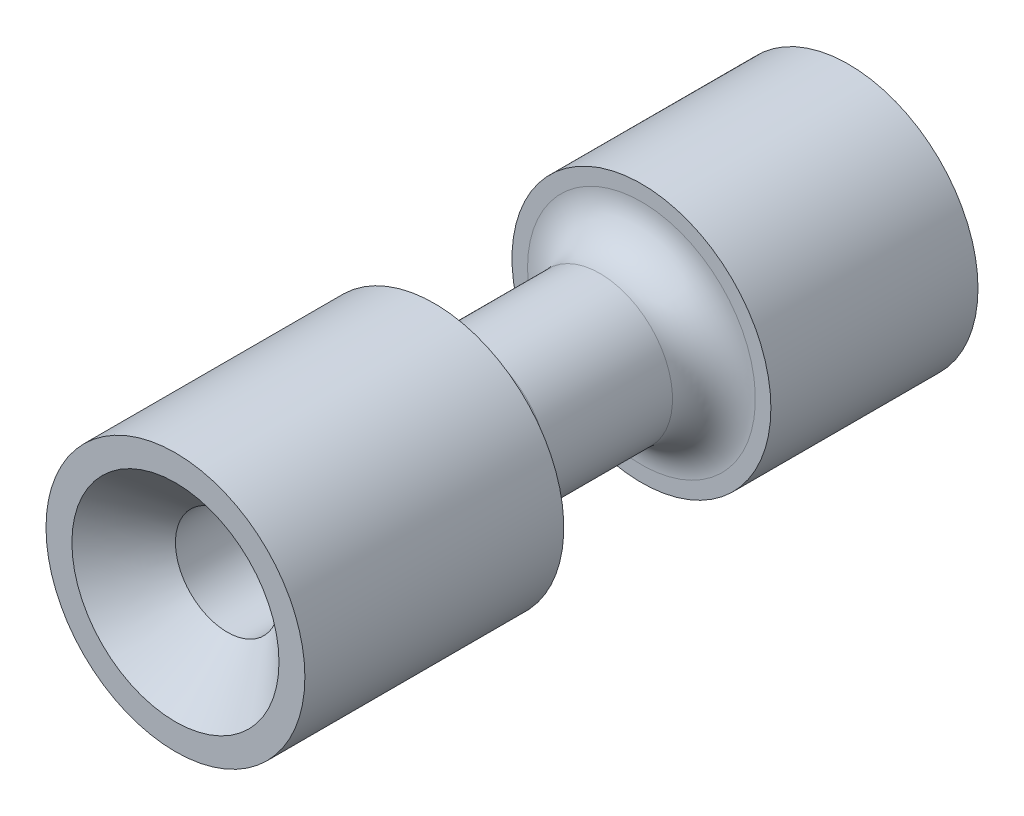
from build123d import *

# Parameters (mm, degrees)
SKETCH1_R                = 2.5
BOSS_EXTRUDE1_DEPTH      = 13
F_2_0_2_DIAMETER_HOLE1_D = 2
CHAMFER2_SIZE            = 1


with BuildPart() as part:
    # Sketch1 → Boss-Extrude1 (new body)
    with BuildSketch(Plane.XY):
        Circle(SKETCH1_R)
    extrude(amount=BOSS_EXTRUDE1_DEPTH)

    # Sketch3 → Cut-Revolve1 (revolve, cut)
    with BuildSketch(Plane(origin=(0, 0, 0), x_dir=(1, 0, 0), z_dir=(0, 1, 0))):
        with BuildLine():
            Line((3.138230266, -4), (2.2, -4))
            ThreePointArc((2.2, -4), (1.634314575, -4.234314575), (1.4, -4.8))
            Line((1.4, -4.8), (1.4, -7.2))
            ThreePointArc((1.4, -7.2), (1.634314575, -7.765685425), (2.2, -8))
            Line((2.2, -8), (3.138230266, -8))
            Line((3.138230266, -8), (3.138230266, -4))
        make_face()
    revolve(axis=Axis((0, 0, 0), (0, 0, 1)), mode=Mode.SUBTRACT)

    # Ø2.0 (2) Diameter Hole1 (through all)
    with Locations(Plane.XY.offset(13)):
        with Locations((0, 0)):
            Hole(F_2_0_2_DIAMETER_HOLE1_D / 2)

    # Chamfer2
    chamfer2_edges = [part.edges().sort_by_distance(p)[0] for p in [
        (1, 0, 13),
    ]]
    chamfer(chamfer2_edges, length=CHAMFER2_SIZE)


solid = part.part
